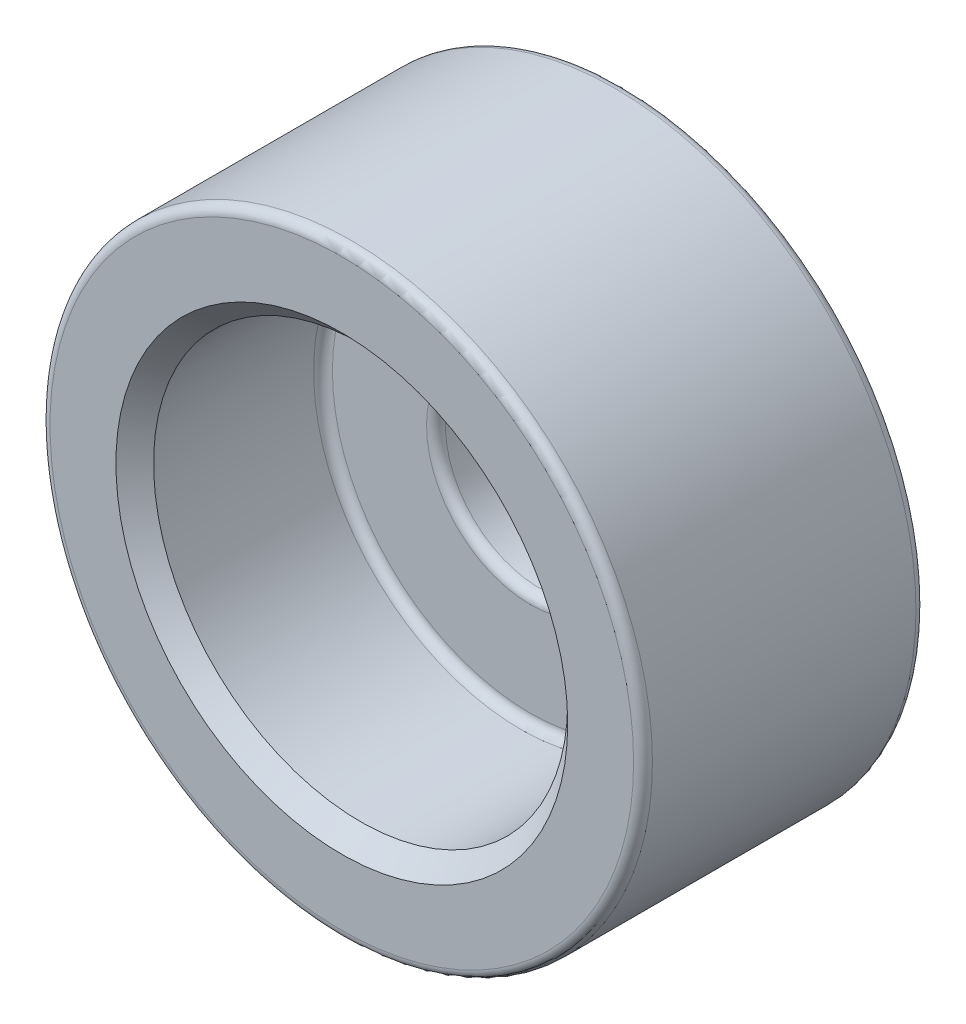
from build123d import *

# Parameters (mm, degrees)
CROQUIS1_R              = 16
SALIENTE_EXTRUIR1_DEPTH = 15
CROQUIS2_R              = 11
CORTAR_EXTRUIR1_DEPTH   = 10
CROQUIS3_R              = 5
CORTAR_EXTRUIR2_DEPTH   = 5
CHAFL_N1_SIZE           = 1
REDONDEO1_R             = 0.5


with BuildPart() as part:
    # Croquis1 → Saliente-Extruir1 (new body)
    with BuildSketch(Plane.XY):
        Circle(CROQUIS1_R)
    extrude(amount=SALIENTE_EXTRUIR1_DEPTH)

    # Croquis2 → Cortar-Extruir1 (cut)
    with BuildSketch(Plane.XY.offset(15)):
        Circle(CROQUIS2_R)
    extrude(amount=-CORTAR_EXTRUIR1_DEPTH, mode=Mode.SUBTRACT)

    # Croquis3 → Cortar-Extruir2 (cut)
    with BuildSketch(Plane.XY.offset(5)):
        Circle(CROQUIS3_R)
    extrude(amount=-CORTAR_EXTRUIR2_DEPTH, mode=Mode.SUBTRACT)

    # Chaflán1
    chafl_n1_edges = [part.edges().sort_by_distance(p)[0] for p in [
        (-11, 0, 15),
    ]]
    chamfer(chafl_n1_edges, length=CHAFL_N1_SIZE)

    # Redondeo1
    redondeo1_edges = [part.edges().sort_by_distance(p)[0] for p in [
        (-5, 0, 5),
        (-5, 0, 0),
        (-16, 0, 0),
        (-16, 0, 15),
        (-11, 0, 5),
    ]]
    fillet(redondeo1_edges, radius=REDONDEO1_R)


solid = part.part
